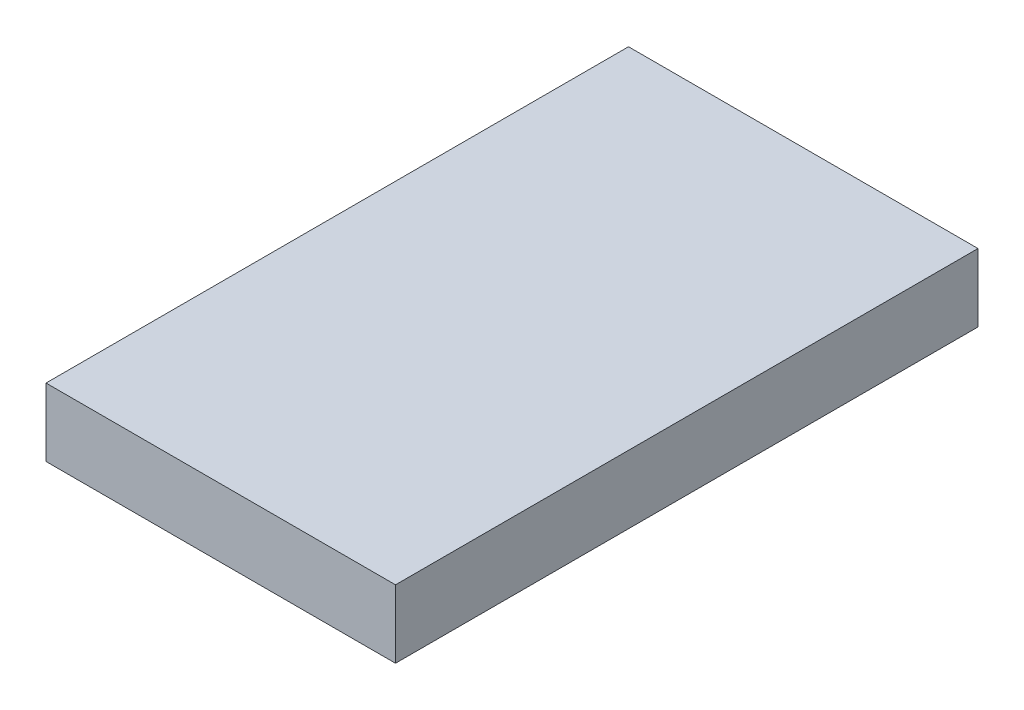
from build123d import *

# Parameters (mm, degrees)
SKETCH1_W           = 36
SKETCH1_H           = 60
BOSS_EXTRUDE1_DEPTH = 3.5


with BuildPart() as part:
    # Sketch1 → Boss-Extrude1 (new body, symmetric)
    with BuildSketch(Plane(origin=(0, 0, 0), x_dir=(1, 0, 0), z_dir=(0, 1, 0))):
        Rectangle(SKETCH1_W, SKETCH1_H)
    extrude(amount=BOSS_EXTRUDE1_DEPTH, both=True)


solid = part.part
